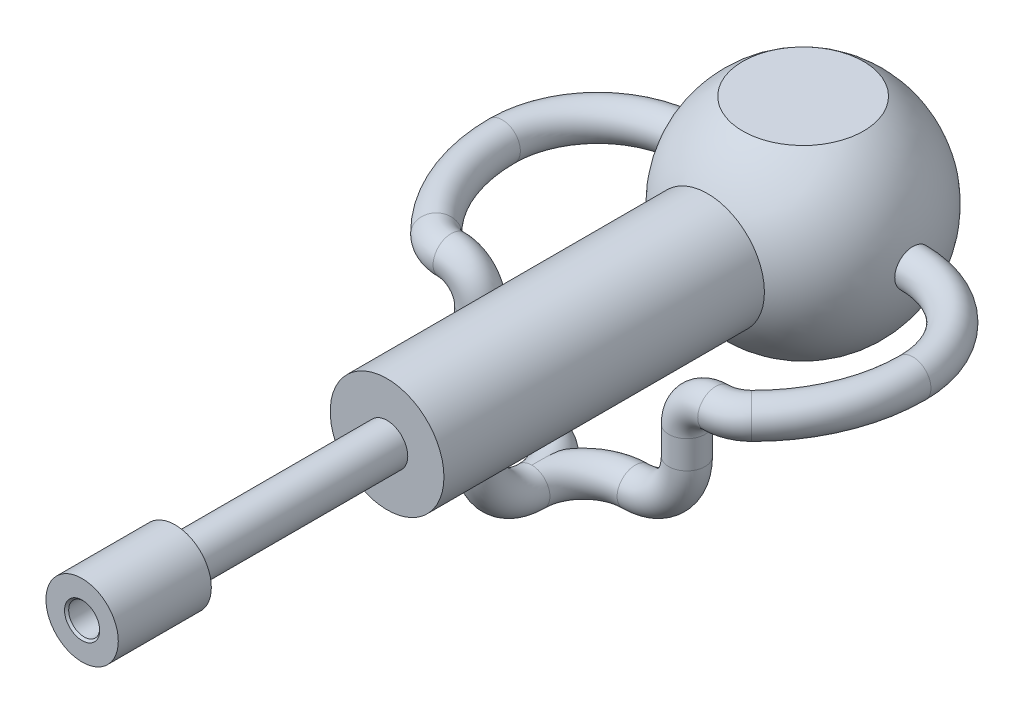
from build123d import *
from build123d.topology import SkipClean

# Parameters (mm, degrees)
DOME1_FACE_RADIUS       = 2.75
DOME1_HEIGHT            = 10
SKETCH2_R               = 0.75
CUT_EXTRUDE1_DEPTH      = 14.75
CHAMFER1_SIZE           = 0.1
SKETCH4_R               = 0.875
CUT_EXTRUDE3_DEPTH      = 32.191520595
CUT_EXTRUDE3_DEPTH_BACK = 32.191520595
SKETCH12_R              = 0.875
SCALE1_SCALE            = 0.5
SCALE2_SCALE            = 0.25
SKETCH13_W              = 1.6
SKETCH13_H              = 0.25
CUT_EXTRUDE4_DEPTH      = 10
CUT_EXTRUDE4_DEPTH_BACK = 10


with BuildPart() as part:
    # Sketch1 → Revolve1 (revolve)
    with BuildSketch(Plane(origin=(0, 0, 0), x_dir=(0, 0, -1), z_dir=(1, 0, 0)), mode=Mode.PRIVATE) as revolve1_sk:
        Polygon((-30.25, 0), (-30.25, 1.75), (-25.75, 1.75), (-25.75, 1), (-15.5, 1), (-15.5, 2.75), (0, 2.75), (0, 0), align=None)
    revolve(revolve1_sk.sketch.rotate(Axis((0, 0, 29.158685325), (0, 0, -1)), 90), axis=Axis((0, 0, 29.158685325), (0, 0, -1)))

    # Dome1: a dome of height H over a round flat face of radius A is a cap of a sphere of radius (A * A + H * H) / (2 * H)
    dome1_r = (DOME1_FACE_RADIUS * DOME1_FACE_RADIUS + DOME1_HEIGHT * DOME1_HEIGHT) / (2 * DOME1_HEIGHT)
    dome1_base = Plane((0, 0, 0), z_dir=(0, 0, -1))
    with Locations(dome1_base.offset(DOME1_HEIGHT - dome1_r)):
        dome1_ball = Sphere(dome1_r, mode=Mode.PRIVATE)
    add(split(dome1_ball, bisect_by=dome1_base, keep=Keep.TOP, mode=Mode.PRIVATE))

    # Sketch2 → Cut-Extrude1 (cut)
    with BuildSketch(Plane.XY.offset(30.25)):
        Circle(SKETCH2_R)
    extrude(amount=-CUT_EXTRUDE1_DEPTH, mode=Mode.SUBTRACT)

    # Chamfer1
    chamfer1_edges = [part.edges().sort_by_distance(p)[0] for p in [
        (-0.75, 0, 30.25),
    ]]
    chamfer(chamfer1_edges, length=CHAMFER1_SIZE)

    # Sketch4 → Cut-Extrude3 (cut, two sides)
    with SkipClean():  # the faces are left unmerged after this step: merging them gives an invalid solid
        with BuildSketch(Plane(origin=(0, 0, 0), x_dir=(0, 0, -1), z_dir=(1, 0, 0))) as cut_extrude3_sk:
            with Locations((4.621875, 0)):
                Circle(SKETCH4_R)
        extrude(amount=CUT_EXTRUDE3_DEPTH, mode=Mode.SUBTRACT)
        extrude(cut_extrude3_sk.sketch, amount=-CUT_EXTRUDE3_DEPTH_BACK, mode=Mode.SUBTRACT)

    # Sweep2: sweep along a curve in space
    with BuildLine() as sweep2_path:
        Line((0, 0, -4.621875), (5.306468083, 0, -4.621875))
        ThreePointArc((5.306468083, 0, -4.621875), (8.574627237, 0, -3.268159154), (9.928343083, 0, 0))
        ThreePointArc((9.928343083, 0, 0), (9.330204478, 0, 2.979036895), (7.628503544, 0, 5.496306159))
        ThreePointArc((7.628503544, 0, 5.496306159), (7.063876578, 0, 5.869187416), (6.4, 0, 6))
        ThreePointArc((6.4, 0, 6), (5.410050506, -0.410050506, 6), (5, -1.4, 6))
        Line((5, -1.4, 6), (5, -2.75, 6))
        ThreePointArc((5, -2.75, 6), (4.267766953, -4.517766953, 6), (2.5, -5.25, 6))
        ThreePointArc((2.5, -5.25, 6), (0.732233047, -5.25, 6.732233047), (0, -5.25, 8.5))
        ThreePointArc((0, -5.25, 8.5), (0, -4.517766953, 10.267766953), (0, -2.75, 11))
        Line((0, -2.75, 11), (0, 0, 11))
    # Sketch12 → Sweep2 (sweep)
    with BuildSketch(Plane(origin=(0, 0, 0), x_dir=(0, 0, -1), z_dir=(1, 0, 0))):
        with Locations((4.621875, 0)):
            Circle(SKETCH12_R)
    sweep2 = sweep(path=sweep2_path.line)

    # Mirror1: Sweep2 across plane
    add(sweep2.mirror(Plane(origin=(0, 0, 0), x_dir=(0, 0, 1), z_dir=(1, 0, 0))))


with BuildPart() as part_1:
    # Scale1: scaled about (5e-09, -0.187958258, 1.30651071)
    add(part.part.scale(SCALE1_SCALE).moved(Location((3e-09, -0.093979129, 0.653255355))))


with BuildPart() as part_2:
    # Scale2: scaled about (5e-09, -0.187958258, 1.30651071)
    add(part_1.part.scale(SCALE2_SCALE).moved(Location((4e-09, -0.140968693, 0.979883032))))

    # Sketch13 → Cut-Extrude4 (cut, two sides)
    with BuildSketch(Plane.XY) as cut_extrude4_sk:
        with Locations((1.05e-07, 0.525)):
            Rectangle(SKETCH13_W, SKETCH13_H)
    extrude(amount=CUT_EXTRUDE4_DEPTH, mode=Mode.SUBTRACT)
    extrude(cut_extrude4_sk.sketch, amount=-CUT_EXTRUDE4_DEPTH_BACK, mode=Mode.SUBTRACT)


solid = part_2.part
